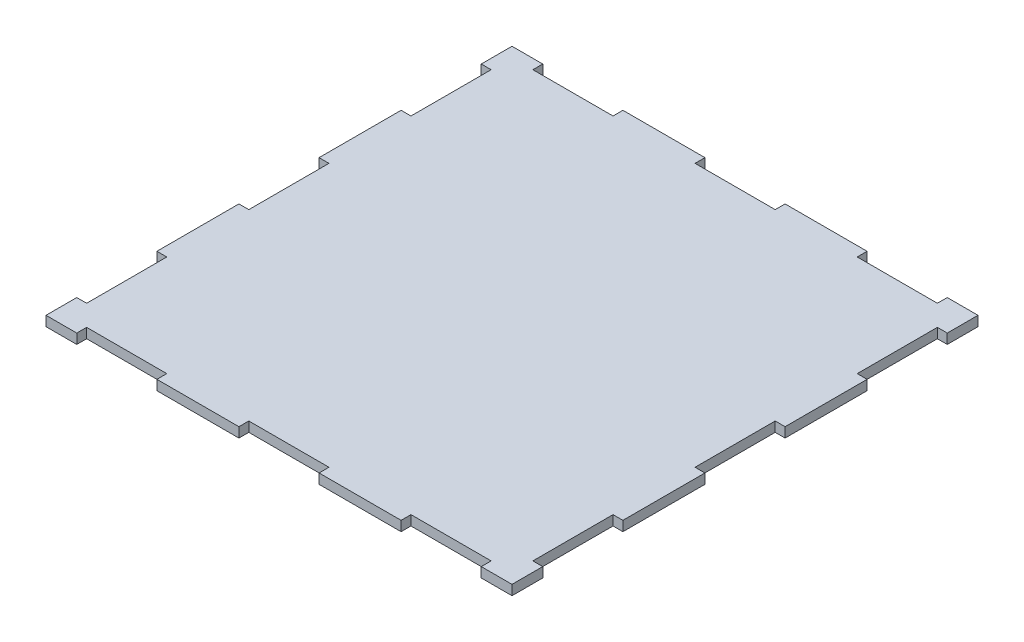
from build123d import *

# Parameters (mm, degrees)
SKETCH1_W                 = 150
SKETCH1_H                 = 150
BOSS_EXTRUDE1_DEPTH       = 3.18
SKETCH6_W                 = 12.9
SKETCH6_H                 = 3.18
SKETCH6_W_2               = 25.8
CUT_EXTRUDE1_DEPTH        = 10
MIRROR2_COPY_1_SKETCH_W   = 12.9
MIRROR2_COPY_1_SKETCH_H   = 3.18
MIRROR2_COPY_1_SKETCH_W_2 = 25.8
MIRROR2_COPY_1_DEPTH      = 10
MIRROR3_COPY_1_SKETCH_W   = 12.9
MIRROR3_COPY_1_SKETCH_H   = 3.18
MIRROR3_COPY_1_SKETCH_W_2 = 25.8
MIRROR3_COPY_1_DEPTH      = 10
MIRROR4_COPY_1_SKETCH_W   = 12.9
MIRROR4_COPY_1_SKETCH_H   = 3.18
MIRROR4_COPY_1_SKETCH_W_2 = 25.8
MIRROR4_COPY_1_DEPTH      = 10
MIRROR4_COPY_2_SKETCH_W   = 12.9
MIRROR4_COPY_2_SKETCH_H   = 3.18
MIRROR4_COPY_2_SKETCH_W_2 = 25.8
MIRROR4_COPY_2_DEPTH      = 10
MIRROR4_COPY_3_SKETCH_W   = 12.9
MIRROR4_COPY_3_SKETCH_H   = 3.18
MIRROR4_COPY_3_SKETCH_W_2 = 25.8
MIRROR4_COPY_3_DEPTH      = 10


with BuildPart() as part:
    # Sketch1 → Boss-Extrude1 (new body)
    with BuildSketch(Plane(origin=(0, 0, 0), x_dir=(1, 0, 0), z_dir=(0, 1, 0))):
        Rectangle(SKETCH1_W, SKETCH1_H)
    extrude(amount=BOSS_EXTRUDE1_DEPTH)

    # Sketch6 → Cut-Extrude1 (cut)
    with BuildSketch(Plane.XZ):
        with Locations((-6.45, 73.41)):
            Rectangle(SKETCH6_W, SKETCH6_H)
        with Locations((-52.2, 73.41)):
            Rectangle(SKETCH6_W_2, SKETCH6_H)
    cut_extrude1 = extrude(amount=-CUT_EXTRUDE1_DEPTH, mode=Mode.SUBTRACT)

    # Mirror1: Cut-Extrude1 across plane
    add(cut_extrude1.mirror(Plane(origin=(0, 0, 0), x_dir=(0, 0, 1), z_dir=(1, 0, 0))), mode=Mode.SUBTRACT)

    # Mirror2: Cut-Extrude1 across plane
    add(cut_extrude1.mirror(Plane.XY), mode=Mode.SUBTRACT)

    # Mirror2 copy 1 sketch → Mirror2 copy 1 (cut)
    with BuildSketch(Plane(origin=(0, 0, 0), x_dir=(-1, 0, 0), z_dir=(0, -1, 0))):
        with Locations((-6.45, 73.41)):
            Rectangle(MIRROR2_COPY_1_SKETCH_W, MIRROR2_COPY_1_SKETCH_H)
        with Locations((-52.2, 73.41)):
            Rectangle(MIRROR2_COPY_1_SKETCH_W_2, MIRROR2_COPY_1_SKETCH_H)
    extrude(amount=-MIRROR2_COPY_1_DEPTH, mode=Mode.SUBTRACT)

    # Mirror3: Cut-Extrude1 across plane
    add(cut_extrude1.mirror(Plane(origin=(0, 0, 0), x_dir=(-0.707106781, 0, 0.707106781), z_dir=(0.707106781, 0, 0.707106781))), mode=Mode.SUBTRACT)

    # Mirror3 copy 1 sketch → Mirror3 copy 1 (cut)
    with BuildSketch(Plane(origin=(0, 0, 0), x_dir=(0, 0, 1), z_dir=(0, -1, 0))):
        with Locations((-6.45, 73.41)):
            Rectangle(MIRROR3_COPY_1_SKETCH_W, MIRROR3_COPY_1_SKETCH_H)
        with Locations((-52.2, 73.41)):
            Rectangle(MIRROR3_COPY_1_SKETCH_W_2, MIRROR3_COPY_1_SKETCH_H)
    extrude(amount=-MIRROR3_COPY_1_DEPTH, mode=Mode.SUBTRACT)

    # Mirror4 copy 1 sketch → Mirror4 copy 1 (cut)
    with BuildSketch(Plane(origin=(0, 0, 0), x_dir=(0, 0, -1), z_dir=(0, -1, 0))):
        with Locations((-6.45, 73.41)):
            Rectangle(MIRROR4_COPY_1_SKETCH_W, MIRROR4_COPY_1_SKETCH_H)
        with Locations((-52.2, 73.41)):
            Rectangle(MIRROR4_COPY_1_SKETCH_W_2, MIRROR4_COPY_1_SKETCH_H)
    extrude(amount=-MIRROR4_COPY_1_DEPTH, mode=Mode.SUBTRACT)

    # Mirror4 copy 2 sketch → Mirror4 copy 2 (cut)
    with BuildSketch(Plane(origin=(0, 0, 0), x_dir=(0, 0, 1), z_dir=(0, -1, 0))):
        with Locations((-6.45, -73.41)):
            Rectangle(MIRROR4_COPY_2_SKETCH_W, MIRROR4_COPY_2_SKETCH_H)
        with Locations((-52.2, -73.41)):
            Rectangle(MIRROR4_COPY_2_SKETCH_W_2, MIRROR4_COPY_2_SKETCH_H)
    extrude(amount=-MIRROR4_COPY_2_DEPTH, mode=Mode.SUBTRACT)

    # Mirror4 copy 3 sketch → Mirror4 copy 3 (cut)
    with BuildSketch(Plane(origin=(0, 0, 0), x_dir=(-1, 0, 0), z_dir=(0, -1, 0))):
        with Locations((-6.45, -73.41)):
            Rectangle(MIRROR4_COPY_3_SKETCH_W, MIRROR4_COPY_3_SKETCH_H)
        with Locations((-52.2, -73.41)):
            Rectangle(MIRROR4_COPY_3_SKETCH_W_2, MIRROR4_COPY_3_SKETCH_H)
    extrude(amount=-MIRROR4_COPY_3_DEPTH, mode=Mode.SUBTRACT)


solid = part.part
